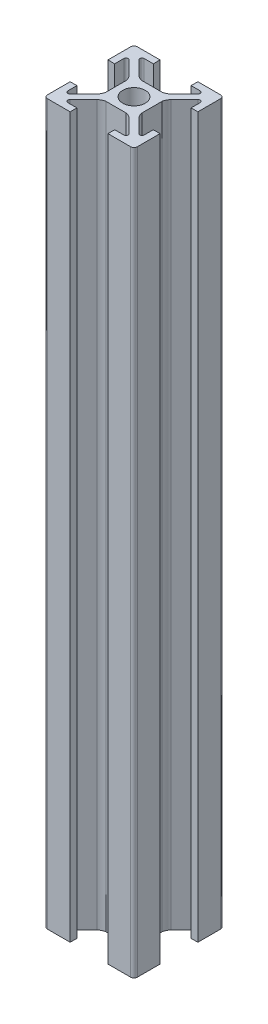
from build123d import *

# Parameters (mm, degrees)
SKETCH1_R           = 2.5
BOSS_EXTRUDE1_DEPTH = 160


with BuildPart() as part:
    # Sketch1 → Boss-Extrude1 (new body)
    with BuildSketch(Plane(origin=(0, 0, 0), x_dir=(1, 0, 0), z_dir=(0, 1, 0))):
        with BuildLine():
            Line((-3.610984523, 4.671644695), (-6.585786438, 7.646446609))
            ThreePointArc((-6.585786438, 7.646446609), (-6.694172813, 8.191341716), (-6.232233047, 8.5))
            Line((-6.232233047, 8.5), (-4.2, 8.5))
            Line((-4.2, 8.5), (-4.2, 10))
            Line((-4.2, 10), (-9.25, 10))
            ThreePointArc((-9.25, 10), (-9.780330086, 9.780330086), (-10, 9.25))
            Line((-10, 9.25), (-10, 4.2))
            Line((-10, 4.2), (-8.5, 4.2))
            Line((-8.5, 4.2), (-8.5, 6.232233047))
            ThreePointArc((-8.5, 6.232233047), (-8.191341716, 6.694172813), (-7.646446609, 6.585786438))
            Line((-7.646446609, 6.585786438), (-4.671644695, 3.610984523))
            ThreePointArc((-4.671644695, 3.610984523), (-4.244383234, 2.985253206), (-4, 2.268058063))
            Line((-4, 2.268058063), (-4, -2.268058063))
            ThreePointArc((-4, -2.268058063), (-4.244383234, -2.985253206), (-4.671644695, -3.610984523))
            Line((-4.671644695, -3.610984523), (-7.646446609, -6.585786438))
            ThreePointArc((-7.646446609, -6.585786438), (-8.191341716, -6.694172813), (-8.5, -6.232233047))
            Line((-8.5, -6.232233047), (-8.5, -4.2))
            Line((-8.5, -4.2), (-10, -4.2))
            Line((-10, -4.2), (-10, -9.25))
            ThreePointArc((-10, -9.25), (-9.780330086, -9.780330086), (-9.25, -10))
            Line((-9.25, -10), (-4.2, -10))
            Line((-4.2, -10), (-4.2, -8.5))
            Line((-4.2, -8.5), (-6.232233047, -8.5))
            ThreePointArc((-6.232233047, -8.5), (-6.694172813, -8.191341716), (-6.585786438, -7.646446609))
            Line((-6.585786438, -7.646446609), (-3.610984523, -4.671644695))
            ThreePointArc((-3.610984523, -4.671644695), (-2.985253206, -4.244383234), (-2.268058063, -4))
            Line((-2.268058063, -4), (2.268058063, -4))
            ThreePointArc((2.268058063, -4), (2.985253206, -4.244383234), (3.610984523, -4.671644695))
            Line((3.610984523, -4.671644695), (6.585786438, -7.646446609))
            ThreePointArc((6.585786438, -7.646446609), (6.694172813, -8.191341716), (6.232233047, -8.5))
            Line((6.232233047, -8.5), (4.2, -8.5))
            Line((4.2, -8.5), (4.2, -10))
            Line((4.2, -10), (9.25, -10))
            ThreePointArc((9.25, -10), (9.780330086, -9.780330086), (10, -9.25))
            Line((10, -9.25), (10, -4.2))
            Line((10, -4.2), (8.5, -4.2))
            Line((8.5, -4.2), (8.5, -6.232233047))
            ThreePointArc((8.5, -6.232233047), (8.191341716, -6.694172813), (7.646446609, -6.585786438))
            Line((7.646446609, -6.585786438), (4.671644695, -3.610984523))
            ThreePointArc((4.671644695, -3.610984523), (4.244383234, -2.985253206), (4, -2.268058063))
            Line((4, -2.268058063), (4, 2.268058063))
            ThreePointArc((4, 2.268058063), (4.244383234, 2.985253206), (4.671644695, 3.610984523))
            Line((4.671644695, 3.610984523), (7.646446609, 6.585786438))
            ThreePointArc((7.646446609, 6.585786438), (8.191341716, 6.694172813), (8.5, 6.232233047))
            Line((8.5, 6.232233047), (8.5, 4.2))
            Line((8.5, 4.2), (10, 4.2))
            Line((10, 4.2), (10, 9.25))
            ThreePointArc((10, 9.25), (9.780330086, 9.780330086), (9.25, 10))
            Line((9.25, 10), (4.2, 10))
            Line((4.2, 10), (4.2, 8.5))
            Line((4.2, 8.5), (6.232233047, 8.5))
            ThreePointArc((6.232233047, 8.5), (6.694172813, 8.191341716), (6.585786438, 7.646446609))
            Line((6.585786438, 7.646446609), (3.610984523, 4.671644695))
            ThreePointArc((3.610984523, 4.671644695), (2.985253206, 4.244383234), (2.268058063, 4))
            Line((2.268058063, 4), (-2.268058063, 4))
            ThreePointArc((-2.268058063, 4), (-2.985253206, 4.244383234), (-3.610984523, 4.671644695))
        make_face()
        Circle(SKETCH1_R, mode=Mode.SUBTRACT)
    extrude(amount=BOSS_EXTRUDE1_DEPTH)


solid = part.part
